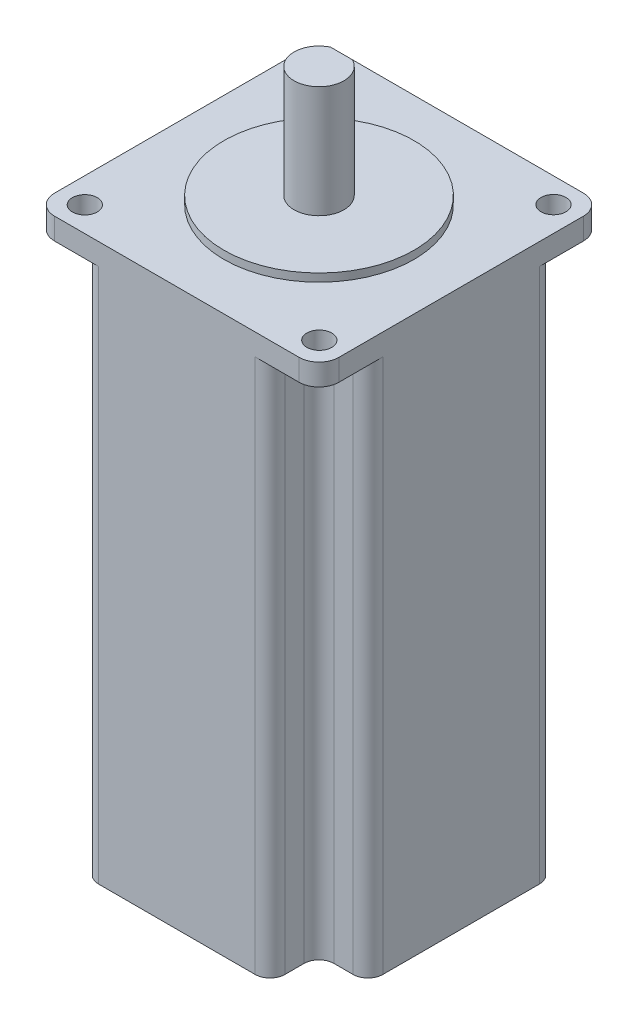
from build123d import *

# Parameters (mm, degrees)
BOSS_EXTRUDE1_DEPTH  = 111.53
SKETCH2_R            = 19.05
BOSS_EXTRUDE2_DEPTH  = 1.6
SKETCH3_R            = 5
BOSS_EXTRUDE3_DEPTH  = 22.4
CUT_EXTRUDE2_DEPTH   = 107.2
MIRROR2_COPY_1_DEPTH = 107.2
FILLET1_R            = 3
SKETCH6_R            = 2.5
CUT_EXTRUDE3_DEPTH   = 107.2
CUT_EXTRUDE4_DEPTH   = 20


with BuildPart() as part:
    # Sketch1 → Boss-Extrude1 (new body)
    with BuildSketch(Plane(origin=(0, 0, 0), x_dir=(1, 0, 0), z_dir=(0, 1, 0))):
        with BuildLine():
            Line((-24.5, -28.5), (24.5, -28.5))
            ThreePointArc((24.5, -28.5), (27.328427125, -27.328427125), (28.5, -24.5))
            Line((28.5, -24.5), (28.5, 24.5))
            ThreePointArc((28.5, 24.5), (27.328427125, 27.328427125), (24.5, 28.5))
            Line((24.5, 28.5), (-24.5, 28.5))
            ThreePointArc((-24.5, 28.5), (-27.328427125, 27.328427125), (-28.5, 24.5))
            Line((-28.5, 24.5), (-28.5, -24.5))
            ThreePointArc((-28.5, -24.5), (-27.328427125, -27.328427125), (-24.5, -28.5))
        make_face()
    extrude(amount=BOSS_EXTRUDE1_DEPTH)

    # Sketch2 → Boss-Extrude2 (add)
    with BuildSketch(Plane(origin=(0, 111.53, 0), x_dir=(1, 0, 0), z_dir=(0, 1, 0))):
        Circle(SKETCH2_R)
    extrude(amount=BOSS_EXTRUDE2_DEPTH)

    # Sketch3 → Boss-Extrude3 (add)
    with BuildSketch(Plane(origin=(0, 113.13, 0), x_dir=(1, 0, 0), z_dir=(0, 1, 0))):
        Circle(SKETCH3_R)
    extrude(amount=BOSS_EXTRUDE3_DEPTH)

    # Sketch5 → Cut-Extrude2 (cut)
    with BuildSketch(Plane.XZ):
        with BuildLine():
            Line((-28.5, 24.5), (-28.5, 18.683107864))
            Line((-28.5, 18.683107864), (-18.683107864, 18.683107864))
            Line((-18.683107864, 18.683107864), (-18.683107864, 28.5))
            Line((-18.683107864, 28.5), (-24.5, 28.5))
            ThreePointArc((-24.5, 28.5), (-27.328427125, 27.328427125), (-28.5, 24.5))
        make_face()
    cut_extrude2 = extrude(amount=-CUT_EXTRUDE2_DEPTH, mode=Mode.SUBTRACT)

    # Mirror1: Cut-Extrude2 across plane
    add(cut_extrude2.mirror(Plane(origin=(0, 0, 0), x_dir=(0, 0, 1), z_dir=(1, 0, 0))), mode=Mode.SUBTRACT)

    # Mirror2: Cut-Extrude2 across plane
    add(cut_extrude2.mirror(Plane.XY), mode=Mode.SUBTRACT)

    # Mirror2 copy 1 sketch → Mirror2 copy 1 (cut)
    with BuildSketch(Plane(origin=(0, 0, 0), x_dir=(-1, 0, 0), z_dir=(0, -1, 0))):
        with BuildLine():
            Line((-28.5, 24.5), (-28.5, 18.683107864))
            Line((-28.5, 18.683107864), (-18.683107864, 18.683107864))
            Line((-18.683107864, 18.683107864), (-18.683107864, 28.5))
            Line((-18.683107864, 28.5), (-24.5, 28.5))
            ThreePointArc((-24.5, 28.5), (-27.328427125, 27.328427125), (-28.5, 24.5))
        make_face()
    extrude(amount=-MIRROR2_COPY_1_DEPTH, mode=Mode.SUBTRACT)

    # Fillet1
    fillet1_edges = [part.edges().sort_by_distance(p)[0] for p in [
        (-18.683107864, 53.6, 28.5),
        (-18.683107864, 53.6, 18.683107864),
        (-28.5, 53.6, 18.683107864),
        (18.683107864, 53.6, 18.683107864),
        (18.683107864, 53.6, 28.5),
        (28.5, 53.6, 18.683107864),
        (18.683107864, 53.6, -28.5),
        (18.683107864, 53.6, -18.683107864),
        (28.5, 53.6, -18.683107864),
        (-18.683107864, 53.6, -18.683107864),
        (-18.683107864, 53.6, -28.5),
        (-28.5, 53.6, -18.683107864),
    ]]
    fillet(fillet1_edges, radius=FILLET1_R)

    # Sketch6 → Cut-Extrude3 (cut)
    with BuildSketch(Plane(origin=(0, 111.53, 0), x_dir=(1, 0, 0), z_dir=(0, 1, 0))):
        with Locations((23.5, 23.5)):
            Circle(SKETCH6_R)
        with Locations((23.564387561, -23.499955896)):
            Circle(SKETCH6_R)
        with Locations((-23.5, 23.5)):
            Circle(SKETCH6_R)
        with Locations((-23.435612439, -23.5)):
            Circle(SKETCH6_R)
    extrude(amount=-CUT_EXTRUDE3_DEPTH, mode=Mode.SUBTRACT)

    # Sketch9 → Cut-Extrude4 (cut)
    with BuildSketch(Plane(origin=(0, 135.53, 0), x_dir=(1, 0, 0), z_dir=(0, 1, 0))):
        with BuildLine():
            Line((0, 4.5), (2.179449472, 4.5))
            ThreePointArc((2.179449472, 4.5), (0, 5), (-2.179449472, 4.5))
            Line((-2.179449472, 4.5), (0, 4.5))
        make_face()
    extrude(amount=-CUT_EXTRUDE4_DEPTH, mode=Mode.SUBTRACT)


solid = part.part
